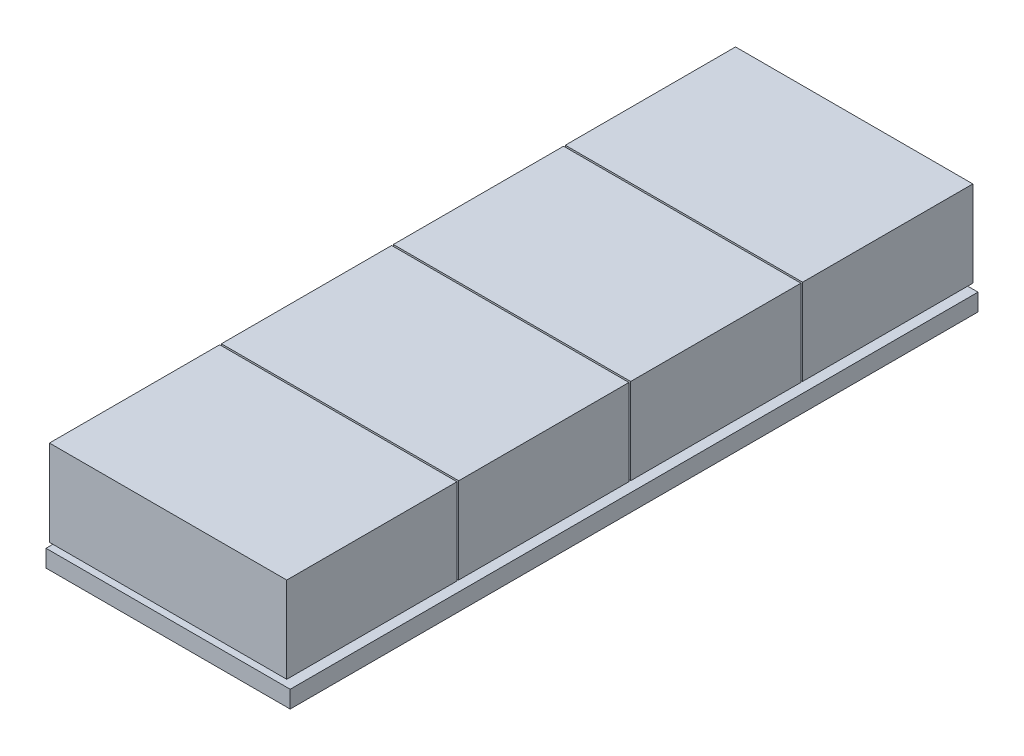
from build123d import *

# Parameters (mm, degrees)
SKETCH1_W           = 71
SKETCH1_H           = 200
BOSS_EXTRUDE1_DEPTH = 5
SKETCH2_W           = 65
SKETCH2_H           = 45
BOSS_EXTRUDE3_DEPTH = 2
LPATTERN1_COUNT     = 4
LPATTERN1_PITCH     = 50
SKETCH3_W           = 69
SKETCH3_H           = 49.5
BOSS_EXTRUDE8_DEPTH = 25
LPATTERN5_COUNT     = 4
LPATTERN5_PITCH     = 50


with BuildPart() as part:
    # Sketch1 → Boss-Extrude1 (new body)
    with BuildSketch(Plane(origin=(0, 0, 0), x_dir=(1, 0, 0), z_dir=(0, 1, 0))):
        Rectangle(SKETCH1_W, SKETCH1_H)
    extrude(amount=BOSS_EXTRUDE1_DEPTH)

    # Sketch2 → Boss-Extrude3 (add)
    with BuildSketch(Plane(origin=(0, 5, 0), x_dir=(1, 0, 0), z_dir=(0, 1, 0))):
        with Locations((0, -75)):
            Rectangle(SKETCH2_W, SKETCH2_H)
    boss_extrude3 = extrude(amount=BOSS_EXTRUDE3_DEPTH)

    # LPattern1: Boss-Extrude3 ×4
    with Locations(*[(0, 0, -i * LPATTERN1_PITCH) for i in range(1, LPATTERN1_COUNT)]):
        add(boss_extrude3)

    # Sketch3 → Boss-Extrude8 (add)
    with BuildSketch(Plane(origin=(0, 7, 0), x_dir=(1, 0, 0), z_dir=(0, 1, 0))):
        with Locations((0, -75.25)):
            Rectangle(SKETCH3_W, SKETCH3_H)
    boss_extrude8 = extrude(amount=BOSS_EXTRUDE8_DEPTH)

    # LPattern5: Boss-Extrude8 ×4
    with Locations(*[(0, 0, -i * LPATTERN5_PITCH) for i in range(1, LPATTERN5_COUNT)]):
        add(boss_extrude8)


solid = part.part
